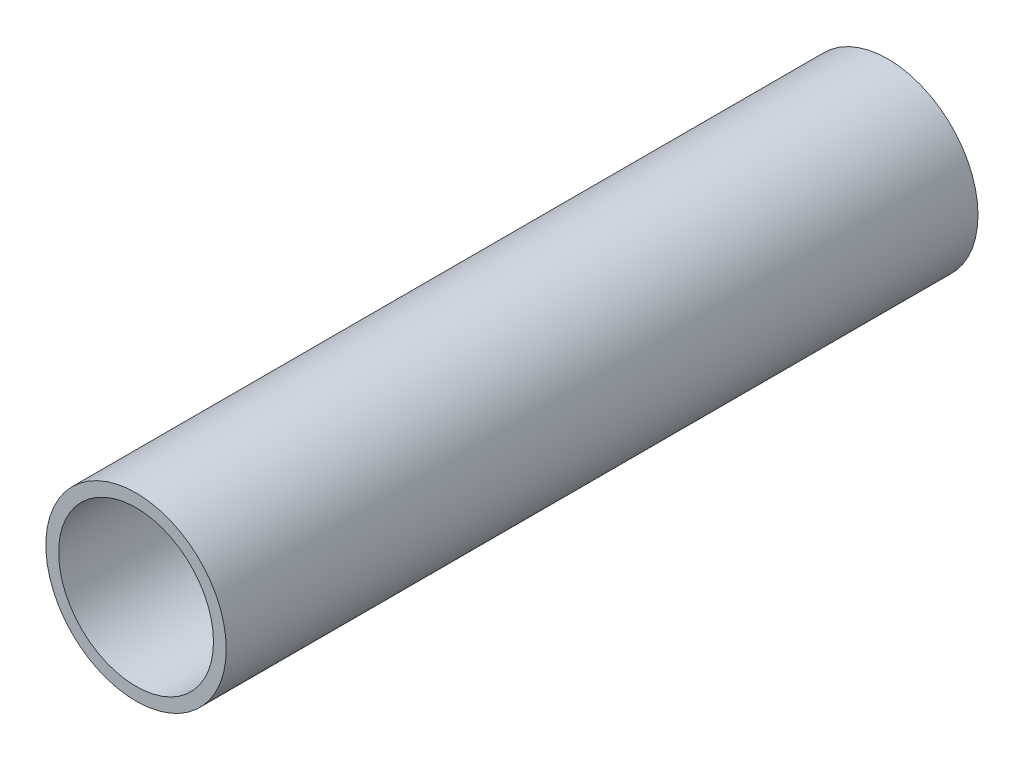
from build123d import *

# Parameters (mm, degrees)
SKETCH1_R           = 24
SKETCH1_R_2         = 20.6
BOSS_EXTRUDE1_DEPTH = 200


with BuildPart() as part:
    # Sketch1 → Boss-Extrude1 (new body)
    with BuildSketch(Plane.XY):
        Circle(SKETCH1_R)
        Circle(SKETCH1_R_2, mode=Mode.SUBTRACT)
    extrude(amount=-BOSS_EXTRUDE1_DEPTH)


solid = part.part
